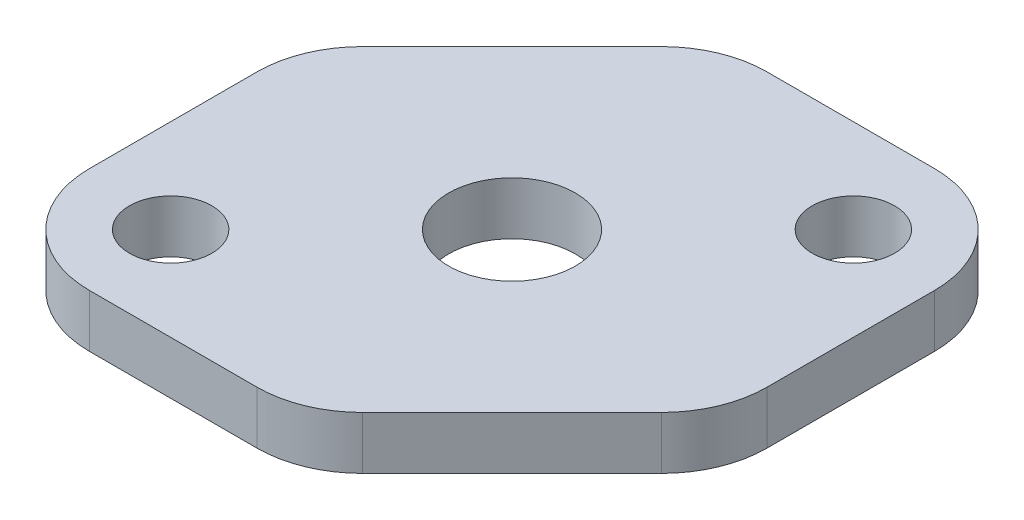
from build123d import *

# Parameters (mm, degrees)
SKETCH1_W           = 31.75
SKETCH1_H           = 31.75
BOSS_EXTRUDE1_DEPTH = 3.175
SKETCH3_R           = 2.4765
CUT_EXTRUDE2_DEPTH  = 4.175
SKETCH2_R           = 3.81
CUT_EXTRUDE4_DEPTH  = 4.175
CUT_EXTRUDE5_DEPTH  = 4.175
FILLET1_R           = 6.35


with BuildPart() as part:
    # Sketch1 → Boss-Extrude1 (new body)
    with BuildSketch(Plane(origin=(0, 0, 0), x_dir=(1, 0, 0), z_dir=(0, 1, 0))):
        Rectangle(SKETCH1_W, SKETCH1_H)
    extrude(amount=BOSS_EXTRUDE1_DEPTH)

    # Sketch3 → Cut-Extrude2 (cut, through all)
    with BuildSketch(Plane.XZ):
        with Locations((-10.262339924, 10.262339924)):
            Circle(SKETCH3_R)
        with Locations((10.262339924, -10.262339924)):
            Circle(SKETCH3_R)
    extrude(amount=-CUT_EXTRUDE2_DEPTH, mode=Mode.SUBTRACT)

    # Sketch2 → Cut-Extrude4 (cut, through all)
    with BuildSketch(Plane.XZ):
        Circle(SKETCH2_R)
    extrude(amount=-CUT_EXTRUDE4_DEPTH, mode=Mode.SUBTRACT)

    # Sketch4 → Cut-Extrude5 (cut, through all)
    with BuildSketch(Plane(origin=(0, 3.175, 0), x_dir=(1, 0, 0), z_dir=(0, 1, 0))):
        Polygon((-15.875, 15.875), (-3.175, 15.875), (-15.875, 3.175), align=None)
        Polygon((15.875, -15.875), (15.875, -3.175), (3.175, -15.875), align=None)
    extrude(amount=-CUT_EXTRUDE5_DEPTH, mode=Mode.SUBTRACT)

    # Fillet1
    fillet1_edges = [part.edges().sort_by_distance(p)[0] for p in [
        (-15.875, 1.5875, -3.175),
        (-3.175, 1.5875, -15.875),
        (3.175, 1.5875, 15.875),
        (15.875, 1.5875, 3.175),
        (-15.875, 1.5875, 15.875),
        (15.875, 1.5875, -15.875),
    ]]
    fillet(fillet1_edges, radius=FILLET1_R)


solid = part.part
